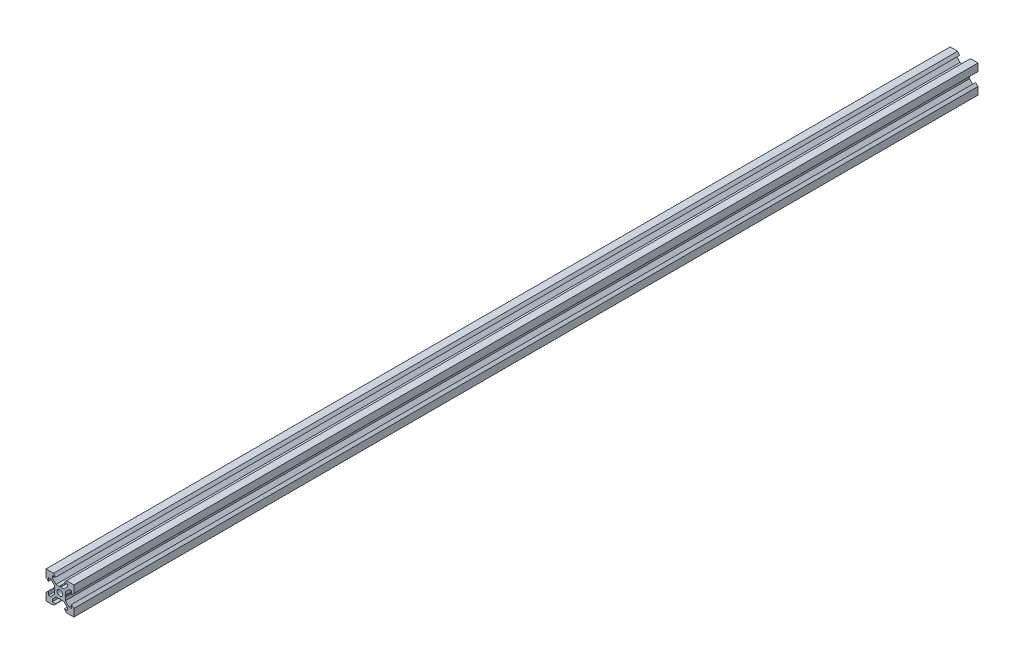
from build123d import *

# Parameters (mm, degrees)
SKETCH1_R           = 2
BOSS_EXTRUDE1_DEPTH = 324.575


with BuildPart() as part:
    # Sketch1 → Boss-Extrude1 (new body, symmetric)
    with BuildSketch(Plane.XY):
        Polygon((10, 10), (10, 4.610379336), (8.2, 3.1), (8.2, 5.5), (6.560660172, 5.5), (3.9, 2.839339828), (3.9, 0.519615242), (3.6, 0), (3.9, -0.519615242), (3.9, -2.839339828), (6.560660172, -5.5), (8.2, -5.5), (8.2, -3.1), (10, -4.610379336), (10, -10), (4.610379336, -10), (3.1, -8.2), (5.5, -8.2), (5.5, -6.560660172), (2.839339828, -3.9), (0.519615242, -3.9), (0, -3.6), (-0.519615242, -3.9), (-2.839339828, -3.9), (-5.5, -6.560660172), (-5.5, -8.2), (-3.1, -8.2), (-4.610379336, -10), (-10, -10), (-10, -4.610379336), (-8.2, -3.1), (-8.2, -5.5), (-6.560660172, -5.5), (-3.9, -2.839339828), (-3.9, -0.519615242), (-3.6, 0), (-3.9, 0.519615242), (-3.9, 2.839339828), (-6.560660172, 5.5), (-8.2, 5.5), (-8.2, 3.1), (-10, 4.610379336), (-10, 10), (-4.610379336, 10), (-3.1, 8.2), (-5.5, 8.2), (-5.5, 6.560660172), (-2.839339828, 3.9), (-0.519615242, 3.9), (0, 3.6), (0.519615242, 3.9), (2.839339828, 3.9), (5.5, 6.560660172), (5.5, 8.2), (3.1, 8.2), (4.610379336, 10), align=None)
        Circle(SKETCH1_R, mode=Mode.SUBTRACT)
    extrude(amount=BOSS_EXTRUDE1_DEPTH, both=True)


solid = part.part
